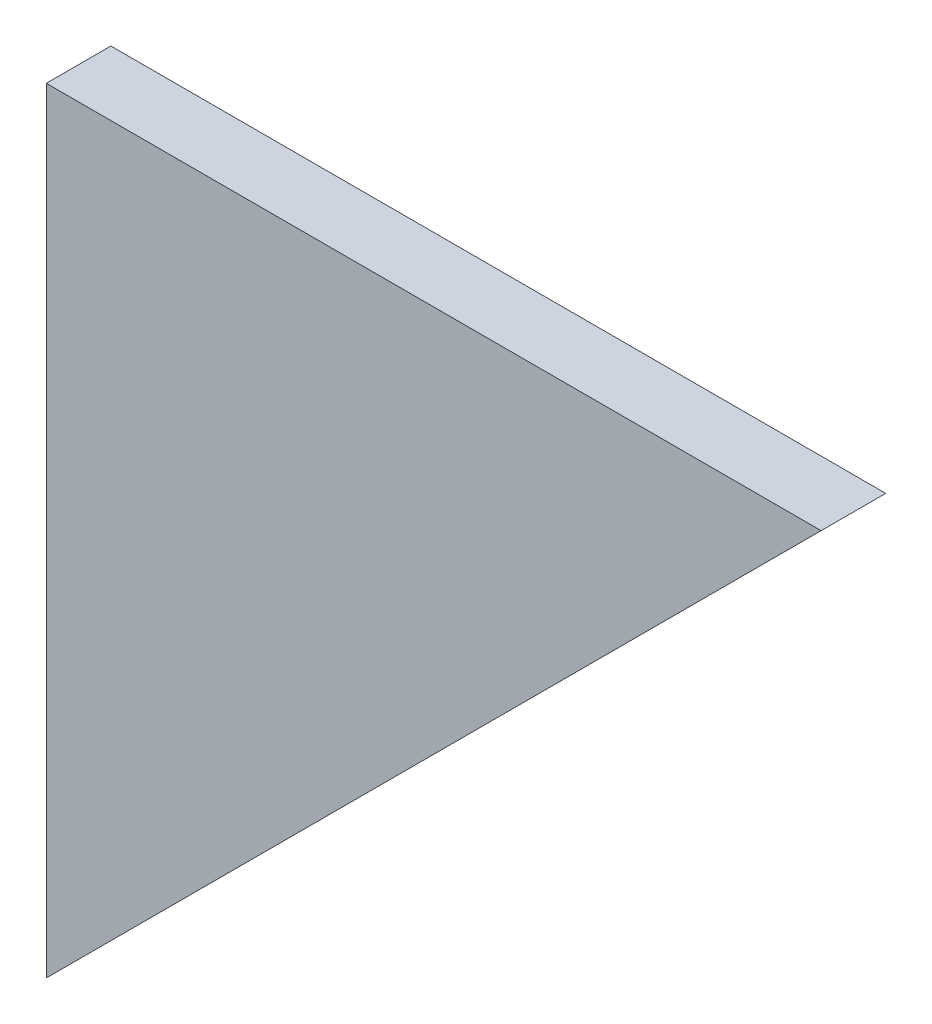
from build123d import *

# Parameters (mm, degrees)
BOSS_EXTRUDE1_DEPTH = 3.175


with BuildPart() as part:
    # Sketch1 → Boss-Extrude1 (new body, symmetric)
    with BuildSketch(Plane.XY):
        Polygon((0, 0), (76.2, 0), (0, -76.2), align=None)
    extrude(amount=BOSS_EXTRUDE1_DEPTH, both=True)


solid = part.part
